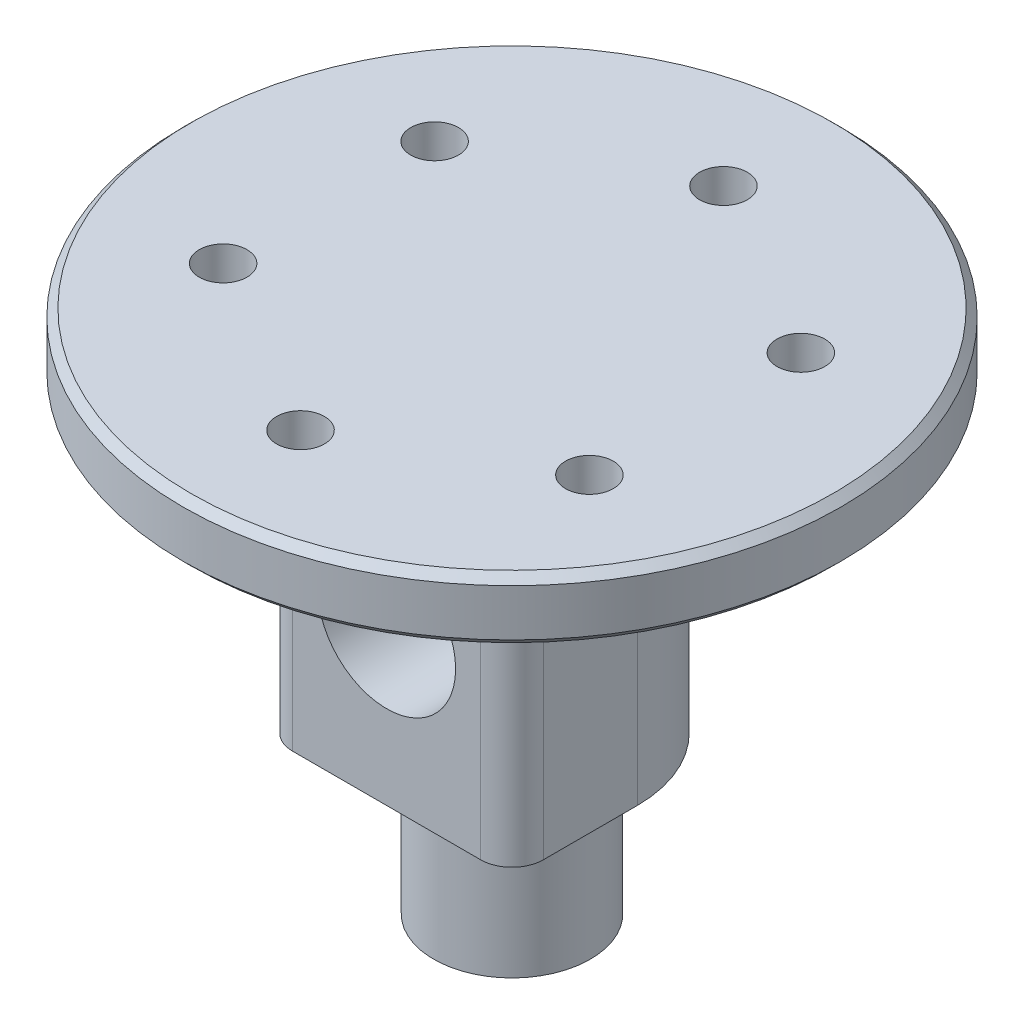
from build123d import *

# Parameters (mm, degrees)
SKETCH_1_R               = 8
EXTRUDE_1_DEPTH          = 19.5
SKETCH_2_R               = 21
EXTRUDE_2_DEPTH          = 4
SKETCH_3_R               = 1.525
CUT_EXTRUDE_1_DEPTH      = 4
SKETCH_5_W               = 16
SKETCH_5_H               = 19.5
EXTRUDE_3_DEPTH          = 8
SKETCH_8_R               = 5
EXTRUDE_4_DEPTH          = 10
HOLE_WIZARD_G1_8_1_D     = 8.8
HOLE_WIZARD_G1_8_1_DEPTH = 11
HOLE_WIZARD_G1_8_1_TIP   = 2.643786724
CUT_EXTRUDE_4_REACH      = 35.5
SKETCH_9_R               = 2.025
FILLET_1_R               = 2
CHAMFER_1_SIZE           = 0.5


with BuildPart() as part:
    # 草图1 → 凸台-拉伸1 (new body)
    with BuildSketch(Plane(origin=(0, 0, 0), x_dir=(1, 0, 0), z_dir=(0, 1, 0))):
        Circle(SKETCH_1_R)
    extrude(amount=EXTRUDE_1_DEPTH)

    # 草图2 → 凸台-拉伸2 (add)
    with BuildSketch(Plane(origin=(0, 19.5, 0), x_dir=(1, 0, 0), z_dir=(0, 1, 0))):
        Circle(SKETCH_2_R)
    extrude(amount=EXTRUDE_2_DEPTH)

    # 草图3 → 切除-拉伸1 (cut)
    with BuildSketch(Plane.XZ.offset(-19.5)):
        with Locations((0, -13.5)):
            Circle(SKETCH_3_R)
        with Locations((-11.691342951, -6.75)):
            Circle(SKETCH_3_R)
        with Locations((-11.691342951, 6.75)):
            Circle(SKETCH_3_R)
        with Locations((0, 13.5)):
            Circle(SKETCH_3_R)
        with Locations((11.691342951, 6.75)):
            Circle(SKETCH_3_R)
        with Locations((11.691342951, -6.75)):
            Circle(SKETCH_3_R)
    extrude(amount=-CUT_EXTRUDE_1_DEPTH, mode=Mode.SUBTRACT)

    # 草图5 → 凸台-拉伸3 (add)
    with BuildSketch(Plane.XY):
        with Locations((0, 9.75)):
            Rectangle(SKETCH_5_W, SKETCH_5_H)
    extrude(amount=EXTRUDE_3_DEPTH)

    # 草图8 → 凸台-拉伸4 (add)
    with BuildSketch(Plane.XZ):
        Circle(SKETCH_8_R)
    extrude(amount=EXTRUDE_4_DEPTH)

    # G1/8 螺纹孔1
    with Locations(Plane(origin=(0, 9.75, 8), x_dir=(1, 0, 0), z_dir=(0, 0, 1))):
        with Locations((0, 0)):
            Hole(HOLE_WIZARD_G1_8_1_D / 2, depth=HOLE_WIZARD_G1_8_1_DEPTH)
            with Locations((0, 0, -(HOLE_WIZARD_G1_8_1_DEPTH + HOLE_WIZARD_G1_8_1_TIP / 2))):  # 118° drill point
                Cone(0, HOLE_WIZARD_G1_8_1_D / 2, HOLE_WIZARD_G1_8_1_TIP, mode=Mode.SUBTRACT)

    # 草图9 → 切除-拉伸4 (cut, up to next)
    with BuildSketch(Plane.XZ.offset(10), mode=Mode.PRIVATE) as cut_extrude_4_sk1:
        Circle(SKETCH_9_R)
    cut_extrude_4_tool1 = extrude(cut_extrude_4_sk1.sketch, amount=-CUT_EXTRUDE_4_REACH, mode=Mode.PRIVATE) & part.part
    add(cut_extrude_4_tool1.solids().sort_by_distance((0, -10, 0))[0], mode=Mode.SUBTRACT)

    # 圆角1
    fillet_1_edges = [part.edges().sort_by_distance(p)[0] for p in [
        (8, 9.75, 8),
        (-8, 9.75, 8),
    ]]
    fillet(fillet_1_edges, radius=FILLET_1_R)

    # 倒角1
    chamfer_1_edges = [part.edges().sort_by_distance(p)[0] for p in [
        (-21, 19.5, 0),
        (-21, 23.5, 0),
    ]]
    chamfer(chamfer_1_edges, length=CHAMFER_1_SIZE)


solid = part.part
